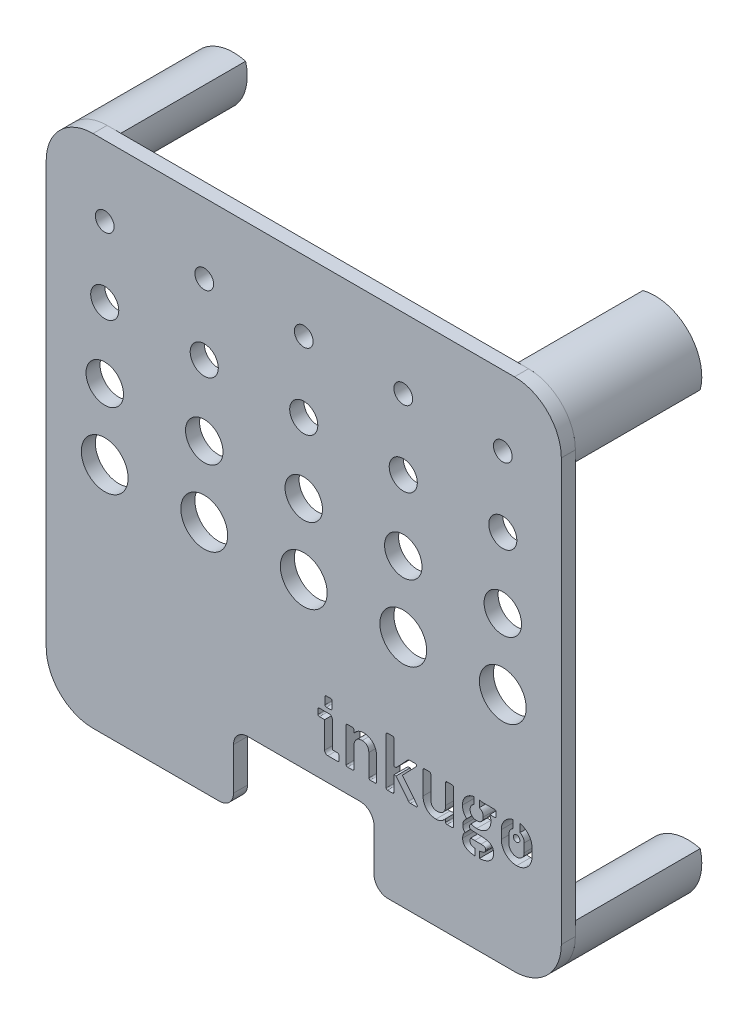
from build123d import *

# Parameters (mm, degrees)
SKETCH1_W             = 110
SKETCH1_H             = 110
BOSS_EXTRUDE1_DEPTH   = 3
FILLET1_R             = 10
SKETCH4_R             = 2
SKETCH4_R_2           = 3
SKETCH4_R_3           = 4
SKETCH4_R_4           = 5
CUT_EXTRUDE1_DEPTH    = 27
BOSS_EXTRUDE5_DEPTH   = 27
BOSS_EXTRUDE5_2_DEPTH = 27
BOSS_EXTRUDE5_3_DEPTH = 27
BOSS_EXTRUDE5_4_DEPTH = 27
SKETCH9_W             = 30
SKETCH9_H             = 15
CUT_EXTRUDE5_DEPTH    = 27
FILLET2_R             = 3
SKETCH10_W            = 1.094584863
SKETCH10_H            = 2.445349162
SKETCH10_W_2          = 0.908272546
SKETCH10_H_2          = 2.049435488
SKETCH10_W_3          = 1.479032729
SKETCH10_H_3          = 2.73682115
BOSS_EXTRUDE6_DEPTH   = 3
SKETCH12_R            = 0.7
CUT_EXTRUDE6_DEPTH    = 3


with BuildPart() as part:
    # Sketch1 → Boss-Extrude1 (new body)
    with BuildSketch(Plane.XY):
        with Locations((55, 55)):
            Rectangle(SKETCH1_W, SKETCH1_H)
    extrude(amount=BOSS_EXTRUDE1_DEPTH)

    # Fillet1
    fillet1_edges = [part.edges().sort_by_distance(p)[0] for p in [
        (0, 110, 1.5),
        (110, 110, 1.5),
        (110, 0, 1.5),
        (0, 0, 1.5),
    ]]
    fillet(fillet1_edges, radius=FILLET1_R)

    # Sketch4 → Cut-Extrude1 (cut)
    with BuildSketch(Plane.XY.offset(3)):
        with Locations((12.5, 95)):
            Circle(SKETCH4_R)
        with Locations((33.75, 95)):
            Circle(SKETCH4_R)
        with Locations((55, 95)):
            Circle(SKETCH4_R)
        with Locations((76.25, 95)):
            Circle(SKETCH4_R)
        with Locations((97.5, 95)):
            Circle(SKETCH4_R)
        with Locations((12.5, 80)):
            Circle(SKETCH4_R_2)
        with Locations((33.75, 80)):
            Circle(SKETCH4_R_2)
        with Locations((55, 80)):
            Circle(SKETCH4_R_2)
        with Locations((76.25, 80)):
            Circle(SKETCH4_R_2)
        with Locations((97.5, 80)):
            Circle(SKETCH4_R_2)
        with Locations((12.5, 65)):
            Circle(SKETCH4_R_3)
        with Locations((33.75, 65)):
            Circle(SKETCH4_R_3)
        with Locations((55, 65)):
            Circle(SKETCH4_R_3)
        with Locations((76.25, 65)):
            Circle(SKETCH4_R_3)
        with Locations((97.5, 65)):
            Circle(SKETCH4_R_3)
        with Locations((12.5, 50)):
            Circle(SKETCH4_R_4)
        with Locations((33.75, 50)):
            Circle(SKETCH4_R_4)
        with Locations((55, 50)):
            Circle(SKETCH4_R_4)
        with Locations((76.25, 50)):
            Circle(SKETCH4_R_4)
        with Locations((97.5, 50)):
            Circle(SKETCH4_R_4)
        with BuildLine():
            add(Edge.make_bspline(
                [(59.813195025, 28.814448571), (59.774303985, 28.817837787), (59.697575515, 28.824524402), (59.601057708, 28.89121158), (59.53437053, 28.987729387), (59.527683915, 29.064457856), (59.524294699, 29.103348897)],
                knots=[0, 0, 0, 0, 1.013731688, 2, 2.986268312, 4, 4, 4, 4], degree=3))
            Line((59.524294699, 29.103348897), (59.524294699, 30.603638177))
            add(Edge.make_bspline(
                [(59.524294699, 30.603638177), (59.52751846, 30.642657736), (59.533832298, 30.719078753), (59.602371745, 30.813729113), (59.696828985, 30.882905841), (59.774179126, 30.889308806), (59.813195025, 30.892538503)],
                knots=[0, 0, 0, 0, 1.014955419, 1.987821677, 2.985044581, 4, 4, 4, 4], degree=3))
            Line((59.813195025, 30.892538503), (60.749630565, 30.892538503))
            add(Edge.make_bspline(
                [(60.749630565, 30.892538503), (60.788777767, 30.889475105), (60.865830971, 30.883445439), (60.958398815, 30.812406427), (61.029437827, 30.719838582), (61.035467494, 30.642785379), (61.038530891, 30.603638177)],
                knots=[0, 0, 0, 0, 1.016108355, 2, 2.983891645, 4, 4, 4, 4], degree=3))
            Line((61.038530891, 30.603638177), (61.038530891, 29.103348897))
            add(Edge.make_bspline(
                [(61.038530891, 29.103348897), (61.035301195, 29.064332998), (61.028898229, 28.986982857), (60.959721501, 28.892525617), (60.865071142, 28.823986169), (60.788650124, 28.817672332), (60.749630565, 28.814448571)],
                knots=[0, 0, 0, 0, 1.014955419, 2.012178323, 2.985044581, 4, 4, 4, 4], degree=3))
            Line((60.749630565, 28.814448571), (59.813195025, 28.814448571))
        make_face()
        with BuildLine():
            add(Edge.make_bspline(
                [(60.143936088, 20), (60.097149113, 20.001952563), (60.005903239, 20.005760531), (59.87588171, 20.045715089), (59.756976775, 20.108749709), (59.653128255, 20.196539005), (59.564651268, 20.300749593), (59.502772585, 20.42092528), (59.462225241, 20.551297895), (59.458475341, 20.642573653), (59.456552553, 20.689375951)],
                knots=[0, 0, 0, 0, 1.032776546, 2.01416311, 2.980907915, 3.993505528, 5.006103142, 5.98583689, 6.967223454, 8, 8, 8, 8], degree=3))
            Line((59.456552553, 20.689375951), (59.456552553, 26.321936102))
            Line((59.456552553, 26.321936102), (58.34079957, 26.321936102))
            add(Edge.make_bspline(
                [(58.34079957, 26.321936102), (58.301213268, 26.325213521), (58.223757812, 26.331626194), (58.126666602, 26.398699201), (58.059983494, 26.495216895), (58.053296325, 26.57194538), (58.049906828, 26.610836428)],
                knots=[0, 0, 0, 0, 1.026560713, 2.008592011, 2.990623309, 4, 4, 4, 4], degree=3))
            Line((58.049906828, 26.610836428), (58.049906828, 27.601067201))
            add(Edge.make_bspline(
                [(58.049906828, 27.601067201), (58.05301505, 27.640785094), (58.059052727, 27.717936537), (58.127978767, 27.813155695), (58.223004026, 27.882722696), (58.301085378, 27.88884565), (58.34079957, 27.891959943)],
                knots=[0, 0, 0, 0, 1.023392815, 1.98792599, 2.976607185, 4, 4, 4, 4], degree=3))
            Line((58.34079957, 27.891959943), (60.418889502, 27.891959943))
            add(Edge.make_bspline(
                [(60.418889502, 27.891959943), (60.465648191, 27.889957377), (60.556838902, 27.886051891), (60.687563383, 27.846705021), (60.805212598, 27.780784126), (60.910029076, 27.693723567), (60.997089635, 27.588907088), (61.06301053, 27.471257873), (61.102357401, 27.340533393), (61.106262887, 27.249342682), (61.108265452, 27.202583993)],
                knots=[0, 0, 0, 0, 1.032642017, 2.013900747, 2.987534287, 4, 5.012465713, 5.986099253, 6.967357983, 8, 8, 8, 8], degree=3))
            Line((61.108265452, 27.202583993), (61.108265452, 21.570023841))
            Line((61.108265452, 21.570023841), (62.224018436, 21.570023841))
            add(Edge.make_bspline(
                [(62.224018436, 21.570023841), (62.263165638, 21.566960444), (62.340218842, 21.560930778), (62.432786686, 21.489891766), (62.503825698, 21.397323921), (62.509855365, 21.320270717), (62.512918762, 21.281123515)],
                knots=[0, 0, 0, 0, 1.016108355, 2, 2.983891645, 4, 4, 4, 4], degree=3))
            Line((62.512918762, 21.281123515), (62.512918762, 20.288900326))
            add(Edge.make_bspline(
                [(62.512918762, 20.288900326), (62.509689066, 20.249884428), (62.5032861, 20.172534286), (62.434109373, 20.078077046), (62.339459013, 20.009537599), (62.263037995, 20.003223762), (62.224018436, 20)],
                knots=[0, 0, 0, 0, 1.014955419, 2.012178323, 2.985044581, 4, 4, 4, 4], degree=3))
            Line((62.224018436, 20), (60.143936088, 20))
        make_face()
        with BuildLine():
            add(Edge.make_bspline(
                [(64.345941521, 20), (64.307050481, 20.003389217), (64.230322011, 20.010075831), (64.133804204, 20.076763009), (64.067117026, 20.173280816), (64.060430411, 20.250009286), (64.057041195, 20.288900326)],
                knots=[0, 0, 0, 0, 1.013731688, 2, 2.986268312, 4, 4, 4, 4], degree=3))
            Line((64.057041195, 20.288900326), (64.057041195, 27.601067201))
            add(Edge.make_bspline(
                [(64.057041195, 27.601067201), (64.060149052, 27.640785184), (64.066186021, 27.717936802), (64.135117181, 27.813154695), (64.229575754, 27.882326213), (64.306925714, 27.888729889), (64.345941521, 27.891959943)],
                knots=[0, 0, 0, 0, 1.0277946, 1.996476396, 2.989410076, 4, 4, 4, 4], degree=3))
            Line((64.345941521, 27.891959943), (65.419853768, 27.891959943))
            add(Edge.make_bspline(
                [(65.419853768, 27.891959943), (65.459702395, 27.889015996), (65.537490317, 27.883269159), (65.630621551, 27.811834984), (65.702055726, 27.718703751), (65.707802562, 27.640915829), (65.71074651, 27.601067201)],
                knots=[0, 0, 0, 0, 1.024545367, 2, 2.975454633, 4, 4, 4, 4], degree=3))
            Line((65.71074651, 27.601067201), (65.71074651, 26.955524403))
            add(Edge.make_bspline(
                [(65.71074651, 26.955524403), (65.776142481, 27.039308866), (65.905149694, 27.20459122), (66.125905145, 27.42523996), (66.366488314, 27.614491176), (66.62185048, 27.777429803), (66.893680098, 27.907978735), (67.180170617, 28.001835245), (67.480324774, 28.059884689), (67.684968613, 28.066120141), (67.788836442, 28.069284971)],
                knots=[0, 0, 0, 0, 1.040903831, 2.053400231, 3.049552216, 4.035445337, 5.016514275, 5.996222133, 6.982974232, 8, 8, 8, 8], degree=3))
            add(Edge.make_bspline(
                [(67.788836442, 28.069284971), (67.916691909, 28.064763318), (68.167724069, 28.055885479), (68.533558681, 27.983702214), (68.880277739, 27.868587069), (69.202731256, 27.703444303), (69.50042083, 27.501032493), (69.766417613, 27.258741642), (69.999113949, 26.980330066), (70.193120139, 26.666157945), (70.351680743, 26.326403935), (70.462664796, 25.9615246), (70.532952217, 25.57683028), (70.540502967, 25.312756393), (70.544347828, 25.178289294)],
                knots=[0, 0, 0, 0, 1.03012054, 2.022544607, 2.994518876, 3.966788102, 4.93368984, 5.888941106, 6.858389822, 7.849426085, 8.858084892, 9.872625224, 10.91673532, 12, 12, 12, 12], degree=3))
            Line((70.544347828, 25.178289294), (70.544347828, 20.288900326))
            add(Edge.make_bspline(
                [(70.544347828, 20.288900326), (70.541118132, 20.249884428), (70.534715166, 20.172534286), (70.465538439, 20.078077046), (70.370888079, 20.009537599), (70.294467061, 20.003223762), (70.255447502, 20)],
                knots=[0, 0, 0, 0, 1.014955419, 2.012178323, 2.985044581, 4, 4, 4, 4], degree=3))
            Line((70.255447502, 20), (69.179542839, 20))
            add(Edge.make_bspline(
                [(69.179542839, 20), (69.140651799, 20.003389217), (69.063923329, 20.010075831), (68.967405523, 20.076763009), (68.900718344, 20.173280816), (68.89403173, 20.250009286), (68.890642513, 20.288900326)],
                knots=[0, 0, 0, 0, 1.013731688, 2, 2.986268312, 4, 4, 4, 4], degree=3))
            Line((68.890642513, 20.288900326), (68.890642513, 24.971078025))
            add(Edge.make_bspline(
                [(68.890642513, 24.971078025), (68.88961417, 25.03024437), (68.887610254, 25.145540837), (68.868692887, 25.312527165), (68.842028807, 25.470292417), (68.800138161, 25.616149419), (68.747624905, 25.752272056), (68.684663365, 25.877842643), (68.607906751, 25.992526943), (68.52034655, 26.096123981), (68.422151044, 26.188513049), (68.314094561, 26.268109649), (68.197428767, 26.336588446), (68.071437182, 26.393149849), (67.934358823, 26.433618393), (67.788859268, 26.466658685), (67.633175879, 26.483843793), (67.526536561, 26.486135525), (67.472042291, 26.487306633)],
                knots=[0, 0, 0, 0, 1.20144891, 2.341243424, 3.410417786, 4.448231723, 5.417856885, 6.371200576, 7.295460221, 8.214486023, 9.121248957, 10.027911514, 10.934975516, 11.865124725, 12.825317511, 13.833595538, 14.892935253, 16, 16, 16, 16], degree=3))
            add(Edge.make_bspline(
                [(67.472042291, 26.487306633), (67.406193538, 26.486041711), (67.277278098, 26.483565307), (67.089264671, 26.456376561), (66.911522167, 26.415425704), (66.744700397, 26.356919245), (66.587626292, 26.283371975), (66.442045627, 26.19052125), (66.30505073, 26.083108921), (66.182327072, 25.956496454), (66.070958023, 25.818093201), (65.974197112, 25.666440631), (65.892103042, 25.503044352), (65.827737847, 25.325909219), (65.771677123, 25.138287283), (65.738344382, 24.936809871), (65.715241311, 24.723892253), (65.712274055, 24.577977327), (65.71074651, 24.502860255)],
                knots=[0, 0, 0, 0, 1.052956461, 2.061426214, 3.033224436, 3.967576965, 4.885035783, 5.802002071, 6.724800171, 7.664155558, 8.616822253, 9.563125276, 10.537418938, 11.536211118, 12.575565151, 13.665830152, 14.798368278, 16, 16, 16, 16], degree=3))
            Line((65.71074651, 24.502860255), (65.71074651, 20.288900326))
            add(Edge.make_bspline(
                [(65.71074651, 20.288900326), (65.707516456, 20.249884519), (65.70111278, 20.172534559), (65.631941262, 20.078075986), (65.536723369, 20.009144826), (65.459571751, 20.003107857), (65.419853768, 20)],
                knots=[0, 0, 0, 0, 1.010589924, 2.003523604, 2.9722054, 4, 4, 4, 4], degree=3))
            Line((65.419853768, 20), (64.345941521, 20))
        make_face()
        with BuildLine():
            add(Edge.make_bspline(
                [(72.88942151, 20), (72.850530469, 20.003389217), (72.773802, 20.010075831), (72.677284193, 20.076763009), (72.610597015, 20.173280816), (72.6039104, 20.250009286), (72.600521184, 20.288900326)],
                knots=[0, 0, 0, 0, 1.013731688, 2, 2.986268312, 4, 4, 4, 4], degree=3))
            Line((72.600521184, 20.288900326), (72.600521184, 30.258950201))
            add(Edge.make_bspline(
                [(72.600521184, 30.258950201), (72.603629041, 30.298668185), (72.60966601, 30.375819803), (72.67859717, 30.471037696), (72.773055743, 30.540209214), (72.850405703, 30.546612889), (72.88942151, 30.549842943)],
                knots=[0, 0, 0, 0, 1.0277946, 1.996476396, 2.989410076, 4, 4, 4, 4], degree=3))
            Line((72.88942151, 30.549842943), (73.963333757, 30.549842943))
            add(Edge.make_bspline(
                [(73.963333757, 30.549842943), (74.003182384, 30.546898996), (74.080970306, 30.541152159), (74.17410154, 30.469717984), (74.245535715, 30.376586751), (74.251282551, 30.298798829), (74.254226499, 30.258950201)],
                knots=[0, 0, 0, 0, 1.024545367, 2, 2.975454633, 4, 4, 4, 4], degree=3))
            Line((74.254226499, 30.258950201), (74.254226499, 25.082653324))
            Line((74.254226499, 25.082653324), (74.722444269, 25.082653324))
            Line((74.722444269, 25.082653324), (77.187062913, 27.726589412))
            add(Edge.make_bspline(
                [(77.187062913, 27.726589412), (77.21262253, 27.751799795), (77.262866252, 27.80135701), (77.354379831, 27.852315036), (77.452855262, 27.887442516), (77.522133053, 27.890428835), (77.557652297, 27.891959943)],
                knots=[0, 0, 0, 0, 1.026908898, 2.018642276, 2.984143038, 4, 4, 4, 4], degree=3))
            Line((77.557652297, 27.891959943), (78.810881987, 27.891959943))
            add(Edge.make_bspline(
                [(78.810881987, 27.891959943), (78.850544242, 27.889463647), (78.92695236, 27.88465461), (79.020385055, 27.820745375), (79.09212669, 27.736471511), (79.09855565, 27.664832017), (79.101774729, 27.628961026)],
                knots=[0, 0, 0, 0, 1.072887516, 2.066884899, 3.032059675, 4, 4, 4, 4], degree=3))
            add(Edge.make_bspline(
                [(79.101774729, 27.628961026), (79.097586206, 27.59480189), (79.088312066, 27.519167449), (79.04296178, 27.457537759), (79.018093256, 27.423742173)],
                knots=[0, 0, 0, 0, 0.903269317, 2, 2, 2, 2], degree=3))
            Line((79.018093256, 27.423742173), (76.057363017, 24.337489724))
            Line((76.057363017, 24.337489724), (79.197410699, 20.426377033))
            add(Edge.make_bspline(
                [(79.197410699, 20.426377033), (79.217444635, 20.396861933), (79.254506488, 20.342260367), (79.263166468, 20.277029599), (79.267145261, 20.247059589)],
                knots=[0, 0, 0, 0, 1.081108168, 2, 2, 2, 2], degree=3))
            add(Edge.make_bspline(
                [(79.267145261, 20.247059589), (79.263891676, 20.213096579), (79.257582788, 20.147240354), (79.202177897, 20.061468663), (79.111263916, 20.00897846), (79.041378526, 20.003120755), (79.004146343, 20)],
                knots=[0, 0, 0, 0, 1.000464213, 1.939957509, 2.902490516, 4, 4, 4, 4], degree=3))
            Line((79.004146343, 20), (77.778810477, 20))
            add(Edge.make_bspline(
                [(77.778810477, 20), (77.737375925, 20.002936805), (77.656041267, 20.008701655), (77.539363149, 20.04675957), (77.436913967, 20.115636745), (77.381154956, 20.176077953), (77.352433444, 20.207211268)],
                knots=[0, 0, 0, 0, 1.014431785, 1.991296106, 2.965314988, 4, 4, 4, 4], degree=3))
            Line((77.352433444, 20.207211268), (74.708497356, 23.538530891))
            Line((74.708497356, 23.538530891), (74.254226499, 23.538530891))
            Line((74.254226499, 23.538530891), (74.254226499, 20.288900326))
            add(Edge.make_bspline(
                [(74.254226499, 20.288900326), (74.250996444, 20.249884519), (74.244592769, 20.172534559), (74.175421251, 20.078075986), (74.080203358, 20.009144826), (74.00305174, 20.003107857), (73.963333757, 20)],
                knots=[0, 0, 0, 0, 1.010589924, 2.003523604, 2.9722054, 4, 4, 4, 4], degree=3))
            Line((73.963333757, 20), (72.88942151, 20))
        make_face()
        with BuildLine():
            add(Edge.make_bspline(
                [(83.224083521, 19.820682556), (83.096229221, 19.825198433), (82.845199353, 19.834064931), (82.47872805, 19.906452794), (82.131786608, 20.021482479), (81.807092662, 20.183950976), (81.511258237, 20.388657783), (81.246397905, 20.631784134), (81.013736419, 20.909584147), (80.819862027, 21.223837252), (80.660788702, 21.564083209), (80.550604696, 21.929881443), (80.4799058, 22.315110534), (80.472396095, 22.579197096), (80.468572134, 22.713670649)],
                knots=[0, 0, 0, 0, 1.029531539, 2.021388161, 2.997879315, 3.967187475, 4.936569502, 5.887321453, 6.85621586, 7.84668547, 8.854767548, 9.87384161, 10.917354707, 12, 12, 12, 12], degree=3))
            Line((80.468572134, 22.713670649), (80.468572134, 27.601067201))
            add(Edge.make_bspline(
                [(80.468572134, 27.601067201), (80.471679992, 27.640785184), (80.47771696, 27.717936802), (80.54664812, 27.813154695), (80.641106694, 27.882326213), (80.718456654, 27.888729889), (80.75747246, 27.891959943)],
                knots=[0, 0, 0, 0, 1.0277946, 1.996476396, 2.989410076, 4, 4, 4, 4], degree=3))
            Line((80.75747246, 27.891959943), (81.831384707, 27.891959943))
            add(Edge.make_bspline(
                [(81.831384707, 27.891959943), (81.871233335, 27.889015996), (81.949021257, 27.883269159), (82.04215249, 27.811834984), (82.113586665, 27.718703751), (82.119333502, 27.640915829), (82.122277449, 27.601067201)],
                knots=[0, 0, 0, 0, 1.024545367, 2, 2.975454633, 4, 4, 4, 4], degree=3))
            Line((82.122277449, 27.601067201), (82.122277449, 22.918889502))
            add(Edge.make_bspline(
                [(82.122277449, 22.918889502), (82.123253477, 22.859715573), (82.125144548, 22.745064997), (82.144684179, 22.578183221), (82.170252476, 22.420845208), (82.213242516, 22.275291245), (82.265103633, 22.139581247), (82.328620011, 22.014785944), (82.402740444, 21.898818165), (82.490705863, 21.795904586), (82.588785807, 21.703502127), (82.697134013, 21.623218032), (82.815160693, 21.555946261), (82.941428501, 21.498715687), (83.07857667, 21.458368561), (83.224056235, 21.425293502), (83.379745281, 21.408118233), (83.486383807, 21.405825123), (83.540877671, 21.40465331)],
                knots=[0, 0, 0, 0, 1.202114207, 2.329118383, 3.412174328, 4.437583134, 5.407745221, 6.361616823, 7.278969009, 8.198503717, 9.105768768, 10.012933385, 10.932170781, 11.862835056, 12.823559545, 13.832395901, 14.892322221, 16, 16, 16, 16], degree=3))
            add(Edge.make_bspline(
                [(83.540877671, 21.40465331), (83.60674169, 21.405858976), (83.735687015, 21.408219371), (83.922696667, 21.436122178), (84.101269972, 21.474028436), (84.267210252, 21.535343074), (84.425027035, 21.607876193), (84.569210125, 21.702048119), (84.705180589, 21.808827303), (84.829405184, 21.933396048), (84.939557249, 22.072594795), (85.039159957, 22.222828187), (85.120455991, 22.387078423), (85.185979075, 22.563646942), (85.237924203, 22.752304143), (85.275499001, 22.952845457), (85.297424078, 23.166127788), (85.300559392, 23.312008047), (85.302173453, 23.387107272)],
                knots=[0, 0, 0, 0, 1.053674742, 2.062832429, 3.022533671, 3.971093134, 4.889177802, 5.797790087, 6.721217679, 7.653664046, 8.606980608, 9.559703832, 10.534662115, 11.534135627, 12.571313147, 13.664237883, 14.797548578, 16, 16, 16, 16], degree=3))
            Line((85.302173453, 23.387107272), (85.302173453, 27.601067201))
            add(Edge.make_bspline(
                [(85.302173453, 27.601067201), (85.30528131, 27.640785184), (85.311318279, 27.717936802), (85.380249439, 27.813154695), (85.474708012, 27.882326213), (85.552057972, 27.888729889), (85.591073779, 27.891959943)],
                knots=[0, 0, 0, 0, 1.0277946, 1.996476396, 2.989410076, 4, 4, 4, 4], degree=3))
            Line((85.591073779, 27.891959943), (86.666978442, 27.891959943))
            add(Edge.make_bspline(
                [(86.666978442, 27.891959943), (86.706125456, 27.888896111), (86.783178289, 27.882865589), (86.875748842, 27.811832838), (86.947189299, 27.718704319), (86.952935266, 27.640916021), (86.955878768, 27.601067201)],
                knots=[0, 0, 0, 0, 1.011732958, 1.991387932, 2.971042906, 4, 4, 4, 4], degree=3))
            Line((86.955878768, 27.601067201), (86.955878768, 20.288900326))
            add(Edge.make_bspline(
                [(86.955878768, 20.288900326), (86.952649071, 20.249884428), (86.946246106, 20.172534286), (86.877069378, 20.078077046), (86.782419018, 20.009537599), (86.705998001, 20.003223762), (86.666978442, 20)],
                knots=[0, 0, 0, 0, 1.014955419, 2.012178323, 2.985044581, 4, 4, 4, 4], degree=3))
            Line((86.666978442, 20), (85.591073779, 20))
            add(Edge.make_bspline(
                [(85.591073779, 20), (85.552182738, 20.003389217), (85.475454269, 20.010075831), (85.378936462, 20.076763009), (85.312249284, 20.173280816), (85.305562669, 20.250009286), (85.302173453, 20.288900326)],
                knots=[0, 0, 0, 0, 1.013731688, 2, 2.986268312, 4, 4, 4, 4], degree=3))
            Line((85.302173453, 20.288900326), (85.302173453, 20.93643554))
            add(Edge.make_bspline(
                [(85.302173453, 20.93643554), (85.236801966, 20.852622204), (85.107843052, 20.687282892), (84.88644096, 20.466757483), (84.646517366, 20.275534891), (84.391563338, 20.110491404), (84.119581646, 19.97952191), (83.832350763, 19.888718351), (83.532646165, 19.829920305), (83.327968512, 19.823792665), (83.224083521, 19.820682556)],
                knots=[0, 0, 0, 0, 1.040184036, 2.051980287, 3.05149353, 4.040198147, 5.020588668, 5.997607763, 6.983677514, 8, 8, 8, 8], degree=3))
        make_face()
        with BuildLine():
            add(Edge.make_bspline(
                [(91.944888537, 17.148852644), (91.833280743, 17.150503394), (91.615159095, 17.153729552), (91.296505841, 17.175316414), (90.995092715, 17.212816606), (90.711364177, 17.265972103), (90.445484872, 17.336530274), (90.195585277, 17.418801352), (89.964282424, 17.519378177), (89.749409274, 17.631140197), (89.557906377, 17.76337852), (89.387863357, 17.910082808), (89.247858306, 18.078382741), (89.130193939, 18.260961193), (89.040417346, 18.462038945), (88.977304914, 18.679971955), (88.935635836, 18.91387416), (88.932151364, 19.075996244), (88.930363066, 19.15920043)],
                knots=[0, 0, 0, 0, 1.309557742, 2.559345399, 3.745333508, 4.871733681, 5.943460254, 6.971073302, 7.955434123, 8.900193972, 9.808044252, 10.680417822, 11.526535541, 12.367469814, 13.22201464, 14.099801128, 15.024781231, 16, 16, 16, 16], degree=3))
            add(Edge.make_bspline(
                [(88.930363066, 19.15920043), (88.931871891, 19.221700814), (88.934836803, 19.344516982), (88.958968736, 19.525560146), (89.001236041, 19.699559226), (89.059297438, 19.866693944), (89.1310594, 20.028278416), (89.221609838, 20.182330927), (89.329456838, 20.329629788), (89.411109426, 20.421690789), (89.452376069, 20.46821777)],
                knots=[0, 0, 0, 0, 1.03764953, 2.03902969, 3.026095819, 4.006174766, 4.97370049, 5.957310148, 6.967638938, 8, 8, 8, 8], degree=3))
            add(Edge.make_bspline(
                [(89.452376069, 20.46821777), (89.412810574, 20.501688753), (89.334350347, 20.568063279), (89.235924601, 20.685545692), (89.149163872, 20.808822492), (89.078107989, 20.942365727), (89.024845486, 21.085946108), (88.987423647, 21.239123515), (88.962392056, 21.401180498), (88.959658113, 21.512810377), (88.95825689, 21.570023841)],
                knots=[0, 0, 0, 0, 0.992569303, 1.968311382, 2.929721406, 3.881627407, 4.861437691, 5.859634357, 6.903002194, 8, 8, 8, 8], degree=3))
            add(Edge.make_bspline(
                [(88.95825689, 21.570023841), (88.960662551, 21.647304846), (88.965451322, 21.801142438), (89.012604836, 22.027451203), (89.081091057, 22.249172041), (89.18260639, 22.461097044), (89.304468238, 22.665211313), (89.454448213, 22.851320996), (89.619667423, 23.028641082), (89.746545314, 23.130257785), (89.811010956, 23.181888419)],
                knots=[0, 0, 0, 0, 0.980363973, 1.951538199, 2.925346916, 3.921696138, 4.928667228, 5.93789737, 6.952262145, 8, 8, 8, 8], degree=3))
            add(Edge.make_bspline(
                [(89.811010956, 23.181888419), (89.740417336, 23.245444487), (89.599736648, 23.37210057), (89.4161013, 23.589224384), (89.258007039, 23.826289275), (89.123778815, 24.081584868), (89.018837087, 24.354502202), (88.942343524, 24.640869668), (88.898434847, 24.939836412), (88.891859404, 25.142950068), (88.888522329, 25.246031439)],
                knots=[0, 0, 0, 0, 0.975475713, 1.943951805, 2.913317632, 3.899554035, 4.902307536, 5.912353716, 6.940507277, 8, 8, 8, 8], degree=3))
            add(Edge.make_bspline(
                [(88.888522329, 25.246031439), (88.893462353, 25.382526811), (88.903133018, 25.649732171), (88.980039711, 26.037998734), (89.109369841, 26.40120558), (89.286433811, 26.73818666), (89.508963853, 27.043173022), (89.767486852, 27.315708788), (90.065272241, 27.547466163), (90.395230847, 27.740711667), (90.751406228, 27.893744635), (91.129373437, 28.003620164), (91.525395025, 28.071039191), (91.795855682, 28.079130793), (91.932934041, 28.083231883)],
                knots=[0, 0, 0, 0, 1.05469476, 2.064686079, 3.045584585, 4.026294936, 4.99684501, 5.955588664, 6.921100423, 7.903851684, 8.904362384, 9.910116178, 10.940778123, 12, 12, 12, 12], degree=3))
            add(Edge.make_bspline(
                [(91.932934041, 28.083231883), (92.03267009, 28.080983681), (92.230798814, 28.076517557), (92.523968549, 28.039230081), (92.811003921, 27.9807155), (92.996014042, 27.921548592), (93.088535346, 27.891959943)],
                knots=[0, 0, 0, 0, 1.016908952, 2.020120848, 3.0098866, 4, 4, 4, 4], degree=3))
            Line((93.088535346, 27.891959943), (95.802205995, 27.891959943))
            add(Edge.make_bspline(
                [(95.802205995, 27.891959943), (95.841353009, 27.888896111), (95.918405843, 27.882865589), (96.010976395, 27.811832838), (96.082416852, 27.718704319), (96.088162819, 27.640916021), (96.091106321, 27.601067201)],
                knots=[0, 0, 0, 0, 1.011732958, 1.991387932, 2.971042906, 4, 4, 4, 4], degree=3))
            Line((96.091106321, 27.601067201), (96.091106321, 26.692525486))
            add(Edge.make_bspline(
                [(96.091106321, 26.692525486), (96.087876625, 26.653509587), (96.081473659, 26.576159445), (96.012296932, 26.481702206), (95.917646572, 26.413162758), (95.841225554, 26.406848921), (95.802205995, 26.40362516)],
                knots=[0, 0, 0, 0, 1.014955419, 2.012178323, 2.985044581, 4, 4, 4, 4], degree=3))
            Line((95.802205995, 26.40362516), (94.728293748, 26.40362516))
            add(Edge.make_bspline(
                [(94.728293748, 26.40362516), (94.764172418, 26.313311395), (94.836303885, 26.131742108), (94.908422196, 25.845413615), (94.954145158, 25.549041004), (94.958967243, 25.34781746), (94.961406425, 25.246031439)],
                knots=[0, 0, 0, 0, 0.979987643, 1.970194221, 2.973252086, 4, 4, 4, 4], degree=3))
            add(Edge.make_bspline(
                [(94.961406425, 25.246031439), (94.956447609, 25.112186127), (94.946718492, 24.84958379), (94.869579473, 24.467320832), (94.740489862, 24.10872381), (94.56359367, 23.775489935), (94.340207441, 23.475250586), (94.084742276, 23.203874926), (93.787472348, 22.974976444), (93.461870305, 22.77930863), (93.107956004, 22.625914898), (92.733149496, 22.516641093), (92.339196745, 22.448631163), (92.070024005, 22.440742516), (91.932934041, 22.43672482)],
                knots=[0, 0, 0, 0, 1.043186406, 2.046714847, 3.026384337, 4.006464447, 4.977083997, 5.936837178, 6.903469001, 7.892946328, 8.892645159, 9.902169801, 10.931572845, 12, 12, 12, 12], degree=3))
            add(Edge.make_bspline(
                [(91.932934041, 22.43672482), (91.827173566, 22.439291202), (91.616154845, 22.444411779), (91.301309783, 22.489577421), (90.986939205, 22.554463214), (90.782719763, 22.623206492), (90.679704351, 22.657883)],
                knots=[0, 0, 0, 0, 0.992067919, 1.979424765, 2.98075134, 4, 4, 4, 4], degree=3))
            add(Edge.make_bspline(
                [(90.679704351, 22.657883), (90.635146312, 22.610973241), (90.550444693, 22.52180117), (90.460277332, 22.368426591), (90.398792829, 22.212832832), (90.392105241, 22.105198402), (90.388811608, 22.052188523)],
                knots=[0, 0, 0, 0, 1.122370757, 2.133545889, 3.080772711, 4, 4, 4, 4], degree=3))
            add(Edge.make_bspline(
                [(90.388811608, 22.052188523), (90.391297179, 22.009330534), (90.395920116, 21.929618532), (90.435249802, 21.819147471), (90.502330216, 21.730456845), (90.599229978, 21.667644632), (90.716632299, 21.620676368), (90.858060173, 21.587416217), (91.021248109, 21.555622258), (91.139114819, 21.546810307), (91.201717354, 21.542130017)],
                knots=[0, 0, 0, 0, 0.951285315, 1.769305018, 2.570197876, 3.377606579, 4.305069671, 5.373017677, 6.604731118, 8, 8, 8, 8], degree=3))
            add(Edge.make_bspline(
                [(91.201717354, 21.542130017), (91.386987078, 21.534491354), (91.758753775, 21.519163431), (92.130822069, 21.515882216), (92.317470337, 21.514236192)],
                knots=[0, 0, 0, 0, 0.996698877, 2, 2, 2, 2], degree=3))
            Line((92.317470337, 21.514236192), (92.937111726, 21.50028928))
            add(Edge.make_bspline(
                [(92.937111726, 21.50028928), (93.031476333, 21.497280594), (93.215827201, 21.491402821), (93.484954854, 21.466417441), (93.740512438, 21.43366733), (93.982679535, 21.38770186), (94.210804882, 21.330244917), (94.426043102, 21.26250375), (94.627237375, 21.182879305), (94.815468154, 21.092490894), (94.986564105, 20.985342291), (95.13730903, 20.856933922), (95.2608571, 20.702878516), (95.363793694, 20.529294129), (95.443947425, 20.334093998), (95.498140646, 20.117290941), (95.532818757, 19.87957078), (95.537016362, 19.713887652), (95.539207077, 19.6274182)],
                knots=[0, 0, 0, 0, 1.238197474, 2.418944841, 3.543863457, 4.616881487, 5.650117501, 6.628222895, 7.574620503, 8.486339379, 9.363652491, 10.215997797, 11.070477527, 11.941539541, 12.855627871, 13.827622844, 14.866243862, 16, 16, 16, 16], degree=3))
            add(Edge.make_bspline(
                [(95.539207077, 19.6274182), (95.536152025, 19.526955814), (95.530210586, 19.331577436), (95.483977834, 19.048339131), (95.406535465, 18.784804904), (95.295671951, 18.540761566), (95.153133013, 18.316492443), (94.980151407, 18.110755094), (94.774183353, 17.927214565), (94.540637011, 17.762012155), (94.281743005, 17.618245489), (94.002890261, 17.49252401), (93.706264949, 17.384345462), (93.389183589, 17.299689284), (93.054400963, 17.232486581), (92.701321405, 17.181949378), (92.329188267, 17.154935418), (92.075099847, 17.150913655), (91.944888537, 17.148852644)],
                knots=[0, 0, 0, 0, 0.980623221, 1.907107538, 2.79350449, 3.655461654, 4.515440476, 5.380660519, 6.271459074, 7.201748643, 8.168637451, 9.15833231, 10.186112998, 11.248026821, 12.359611279, 13.518866834, 14.72850719, 16, 16, 16, 16], degree=3))
        make_face()
        with BuildLine():
            add(Edge.make_bspline(
                [(91.932934041, 23.883218866), (92.034976191, 23.887557002), (92.231035328, 23.895892098), (92.508232299, 23.966243827), (92.751838874, 24.083304057), (92.957482175, 24.247119843), (93.123166376, 24.449928093), (93.239386916, 24.688860135), (93.311227642, 24.957658348), (93.319389035, 25.147263168), (93.323640439, 25.246031439)],
                knots=[0, 0, 0, 0, 1.11287458, 2.138226504, 3.098184256, 4.042680072, 4.986061768, 5.933004036, 6.923267786, 8, 8, 8, 8], degree=3))
            add(Edge.make_bspline(
                [(93.323640439, 25.246031439), (93.319401332, 25.345460764), (93.311262123, 25.53636795), (93.239080405, 25.807691467), (93.122762896, 26.050028781), (92.985200058, 26.224545246), (92.854626868, 26.343064715), (92.749586916, 26.424672462), (92.632574536, 26.488500035), (92.510658399, 26.546709288), (92.377592288, 26.587606049), (92.23683518, 26.617009581), (92.087504534, 26.635616265), (91.985456666, 26.637672128), (91.932934041, 26.638730253)],
                knots=[0, 0, 0, 0, 1.61016637, 3.091566112, 4.517533475, 5.944110964, 6.660726596, 7.375964664, 8.094762763, 8.817745571, 9.563791271, 10.345456871, 11.148429553, 12, 12, 12, 12], degree=3))
            add(Edge.make_bspline(
                [(91.932934041, 26.638730253), (91.880413543, 26.637640675), (91.777710265, 26.635510018), (91.627700412, 26.617160336), (91.486210195, 26.58775899), (91.352321649, 26.545758388), (91.228172093, 26.489566098), (91.110290228, 26.424622443), (91.005135065, 26.342486501), (90.872211426, 26.225224421), (90.73333967, 26.050043195), (90.614953844, 25.807905593), (90.540127448, 25.536651885), (90.53233539, 25.345499234), (90.528280731, 25.246031439)],
                knots=[0, 0, 0, 0, 0.847859521, 1.65798031, 2.436239612, 3.179034236, 3.918414409, 4.63408017, 5.346201415, 6.067629732, 7.494655642, 8.919140384, 10.396850321, 12, 12, 12, 12], degree=3))
            add(Edge.make_bspline(
                [(90.528280731, 25.246031439), (90.532344282, 25.147220359), (90.540152162, 24.957360532), (90.614679266, 24.688684019), (90.732802641, 24.44974658), (90.900567324, 24.2470876), (91.108508223, 24.082606031), (91.354737983, 23.967132729), (91.633413796, 23.895557325), (91.830197044, 23.887451021), (91.932934041, 23.883218866)],
                knots=[0, 0, 0, 0, 1.071950009, 2.059690492, 3.005655517, 3.949414207, 4.895379231, 5.864072975, 6.884870894, 8, 8, 8, 8], degree=3))
        make_face(mode=Mode.SUBTRACT)
        with BuildLine():
            add(Edge.make_bspline(
                [(92.070410748, 18.567452866), (92.142816689, 18.568283233), (92.282385231, 18.569883836), (92.485032352, 18.580278597), (92.673983516, 18.595051324), (92.84940767, 18.619383713), (93.010423699, 18.648703203), (93.157856882, 18.684188757), (93.290737663, 18.728283291), (93.411282928, 18.776506051), (93.515648581, 18.835974696), (93.608112315, 18.898099258), (93.684466877, 18.969812002), (93.750501746, 19.044840861), (93.797358143, 19.130667509), (93.835293242, 19.220902917), (93.854073276, 19.31984448), (93.857732402, 19.387607122), (93.859600354, 19.422199348)],
                knots=[0, 0, 0, 0, 1.580983636, 3.047478938, 4.430044814, 5.718031082, 6.912664638, 8.003018019, 9.02569154, 9.968321281, 10.831768712, 11.644398253, 12.393605671, 13.114049888, 13.815562867, 14.518423614, 15.243668421, 16, 16, 16, 16], degree=3))
            add(Edge.make_bspline(
                [(93.859600354, 19.422199348), (93.857582831, 19.477241148), (93.853828235, 19.579673527), (93.799460699, 19.717585141), (93.712705434, 19.826852474), (93.58618093, 19.895183077), (93.437346864, 19.943581246), (93.261598415, 19.975444843), (93.060582461, 19.998308972), (92.917267741, 19.999415051), (92.841475756, 20)],
                knots=[0, 0, 0, 0, 0.983187636, 1.829704878, 2.618124847, 3.436762005, 4.368869509, 5.426713209, 6.639117373, 8, 8, 8, 8], degree=3))
            Line((92.841475756, 20), (91.49061768, 20))
            add(Edge.make_bspline(
                [(91.49061768, 20), (91.409586217, 20.000202105), (91.254784031, 20.000588204), (91.034167007, 20.008351531), (90.8355055, 20.022173435), (90.710886343, 20.035515785), (90.651810526, 20.041840737)],
                knots=[0, 0, 0, 0, 1.157047795, 2.210419533, 3.151647873, 4, 4, 4, 4], degree=3))
            add(Edge.make_bspline(
                [(90.651810526, 20.041840737), (90.628625944, 19.999255808), (90.581906035, 19.913441712), (90.534181483, 19.771624378), (90.506415235, 19.619882859), (90.502420685, 19.515296561), (90.500386907, 19.462047669)],
                knots=[0, 0, 0, 0, 0.958127143, 1.930749142, 2.946465082, 4, 4, 4, 4], degree=3))
            add(Edge.make_bspline(
                [(90.500386907, 19.462047669), (90.501191751, 19.420098616), (90.502735072, 19.339659614), (90.524081478, 19.224140572), (90.554700146, 19.118516418), (90.599534196, 19.023481973), (90.654871424, 18.937860149), (90.727260971, 18.866202535), (90.808687295, 18.800629335), (90.943119753, 18.731188738), (91.139963836, 18.662348625), (91.411914302, 18.606184026), (91.726938152, 18.573905609), (91.951450046, 18.569687754), (92.070410748, 18.567452866)],
                knots=[0, 0, 0, 0, 0.73354101, 1.406594504, 2.050477934, 2.65402367, 3.241096148, 3.825049872, 4.429938813, 5.064831232, 6.462891627, 8.068803851, 9.917001863, 12, 12, 12, 12], degree=3))
        make_face(mode=Mode.SUBTRACT)
        with BuildLine():
            add(Edge.make_bspline(
                [(100.454497454, 19.820682556), (100.307993065, 19.826018344), (100.018638508, 19.83655683), (99.594501211, 19.921319898), (99.188435811, 20.05728939), (98.804290657, 20.247090064), (98.448914871, 20.483094767), (98.129273408, 20.760716318), (97.847208396, 21.075736823), (97.610522904, 21.428106515), (97.415236226, 21.805385299), (97.277959342, 22.20475057), (97.1929709, 22.619760142), (97.182342539, 22.901882676), (97.176973064, 23.044411712)],
                knots=[0, 0, 0, 0, 1.032620996, 2.039485608, 3.037880839, 4.045529682, 5.052394294, 6.038594437, 7.023948745, 8.025646133, 9.024931058, 10.011542728, 10.995426223, 12, 12, 12, 12], degree=3))
            Line((97.176973064, 23.044411712), (97.176973064, 24.847548231))
            add(Edge.make_bspline(
                [(97.176973064, 24.847548231), (97.182364567, 24.990069383), (97.193036528, 25.272176312), (97.27757691, 25.686683804), (97.41575373, 26.085050115), (97.610370797, 26.461962582), (97.84786198, 26.814330642), (98.128632493, 27.131105871), (98.448414207, 27.40898841), (98.8048537, 27.642794682), (99.188809085, 27.832046515), (99.593842273, 27.9718581), (100.018943231, 28.052590142), (100.3080534, 28.063671759), (100.454497454, 28.069284971)],
                knots=[0, 0, 0, 0, 1.004815596, 1.98893593, 2.971359466, 3.970884937, 4.972823452, 5.961916848, 6.948354388, 7.952874998, 8.9607664, 9.960906653, 10.967130434, 12, 12, 12, 12], degree=3))
            add(Edge.make_bspline(
                [(100.454497454, 28.069284971), (100.600941507, 28.063671759), (100.890051676, 28.052590142), (101.315152634, 27.9718581), (101.720185822, 27.832046515), (102.104141207, 27.642794682), (102.4605807, 27.40898841), (102.780362414, 27.131105871), (103.061132927, 26.814330642), (103.29862411, 26.461962582), (103.493241177, 26.085050115), (103.631417997, 25.686683804), (103.715958379, 25.272176312), (103.72663034, 24.990069383), (103.732021843, 24.847548231)],
                knots=[0, 0, 0, 0, 1.032869566, 2.039093347, 3.0392336, 4.047125002, 5.051645612, 6.038083152, 7.027176548, 8.029115063, 9.028640534, 10.01106407, 10.995184404, 12, 12, 12, 12], degree=3))
            Line((103.732021843, 24.847548231), (103.732021843, 23.044411712))
            add(Edge.make_bspline(
                [(103.732021843, 23.044411712), (103.726652368, 22.901882676), (103.716024007, 22.619760142), (103.631035565, 22.20475057), (103.493758681, 21.805385299), (103.298472003, 21.428106515), (103.061786511, 21.075736823), (102.779721499, 20.760716318), (102.460080036, 20.483094767), (102.10470425, 20.247090064), (101.720559096, 20.05728939), (101.314493696, 19.921319898), (100.890356399, 19.83655683), (100.601001842, 19.826018344), (100.454497454, 19.820682556)],
                knots=[0, 0, 0, 0, 1.004573777, 1.988457272, 2.975068942, 3.974353867, 4.976051255, 5.961405563, 6.947605706, 7.954470318, 8.962119161, 9.960514392, 10.967379004, 12, 12, 12, 12], degree=3))
        make_face()
        with BuildLine():
            add(Edge.make_bspline(
                [(100.454497454, 21.418600222), (100.509704647, 21.420200504), (100.61856199, 21.423355934), (100.778508312, 21.446300483), (100.933554178, 21.480694122), (101.080033568, 21.536051569), (101.222100348, 21.601968352), (101.356850873, 21.683668188), (101.485853187, 21.780228211), (101.605583621, 21.891333138), (101.717273651, 22.011794411), (101.81417396, 22.140946761), (101.897846895, 22.275612698), (101.963000961, 22.418020334), (102.015100125, 22.566064256), (102.053430635, 22.720030524), (102.075333437, 22.880403561), (102.078634702, 22.989223492), (102.080308944, 23.044411712)],
                knots=[0, 0, 0, 0, 1.035516189, 2.04182703, 3.02724225, 4.008868005, 4.973256916, 5.962761013, 6.95969187, 7.991602595, 9.02351332, 10.037893528, 11.016746883, 11.992422134, 12.96984662, 13.95817297, 14.964483811, 16, 16, 16, 16], degree=3))
            Line((102.080308944, 23.044411712), (102.080308944, 24.847548231))
            add(Edge.make_bspline(
                [(102.080308944, 24.847548231), (102.078632004, 24.902735063), (102.07532542, 25.011552257), (102.053461419, 25.171945259), (102.014987404, 25.325837686), (101.963614461, 25.473584376), (101.896599275, 25.61498673), (101.815546485, 25.750612773), (101.716431256, 25.878199617), (101.605809698, 25.998860475), (101.485148839, 26.109482033), (101.357561996, 26.208597262), (101.221935953, 26.289650052), (101.080533599, 26.356665238), (100.932786909, 26.408038181), (100.778894482, 26.446512196), (100.61850148, 26.468376197), (100.509684286, 26.471682781), (100.454497454, 26.473359721)],
                knots=[0, 0, 0, 0, 1.035795995, 2.04237875, 3.030972155, 4.00866075, 4.973310247, 5.963081718, 6.967810444, 8, 9.032189556, 10.036918282, 11.026689753, 11.99133925, 12.969027845, 13.95762125, 14.964204005, 16, 16, 16, 16], degree=3))
            add(Edge.make_bspline(
                [(100.454497454, 26.473359721), (100.399309233, 26.471685479), (100.290489302, 26.468384214), (100.130116265, 26.446481412), (99.976149997, 26.408150902), (99.828106075, 26.356051738), (99.685698439, 26.290897672), (99.551032502, 26.207224737), (99.421880152, 26.110324428), (99.301418879, 25.998634398), (99.190313952, 25.878903964), (99.093753929, 25.74990165), (99.012054094, 25.615151125), (98.94613731, 25.473084346), (98.890779863, 25.326604955), (98.856386224, 25.171559089), (98.833441675, 25.011612767), (98.830286245, 24.902755425), (98.828685963, 24.847548231)],
                knots=[0, 0, 0, 0, 1.035516189, 2.04182703, 3.03015338, 4.007577866, 4.983253117, 5.962106472, 6.97648668, 8.008397405, 9.04030813, 10.037238987, 11.026743084, 11.991131995, 12.97275775, 13.95817297, 14.964483811, 16, 16, 16, 16], degree=3))
            Line((98.828685963, 24.847548231), (98.828685963, 23.044411712))
            add(Edge.make_bspline(
                [(98.828685963, 23.044411712), (98.830283574, 22.989203142), (98.833433738, 22.880343084), (98.856416667, 22.720416549), (98.890668423, 22.565297537), (98.946763958, 22.418524818), (99.010807028, 22.275449384), (99.095120618, 22.141643711), (99.189468316, 22.011097785), (99.301643532, 21.891557791), (99.421183526, 21.779382575), (99.551729452, 21.685034877), (99.685535125, 21.600721287), (99.828610559, 21.536678217), (99.975383278, 21.480582682), (100.13050229, 21.446330926), (100.290428825, 21.423347996), (100.399288883, 21.420197833), (100.454497454, 21.418600222)],
                knots=[0, 0, 0, 0, 1.035226939, 2.041256688, 3.026396652, 4.00774821, 4.983150925, 5.961730857, 6.968377518, 8, 9.031622482, 10.038269143, 11.016849075, 11.99225179, 12.973603348, 13.958743312, 14.964773061, 16, 16, 16, 16], degree=3))
        make_face(mode=Mode.SUBTRACT)
    extrude(amount=-CUT_EXTRUDE1_DEPTH, mode=Mode.SUBTRACT)

    # Sketch9 → Cut-Extrude5 (cut)
    with BuildSketch(Plane.XY.offset(3)):
        with Locations((55, 7.5)):
            Rectangle(SKETCH9_W, SKETCH9_H)
    extrude(amount=-CUT_EXTRUDE5_DEPTH, mode=Mode.SUBTRACT)

    # Fillet2
    fillet2_edges = [part.edges().sort_by_distance(p)[0] for p in [
        (40, 0, 1.5),
        (70, 0, 1.5),
        (70, 15, 1.5),
        (40, 15, 1.5),
    ]]
    fillet(fillet2_edges, radius=FILLET2_R)

    # Sketch10 → Boss-Extrude6 (add)
    with BuildSketch(Plane.XY.offset(3)):
        with Locations((91.934472852, 27.471238921)):
            Rectangle(SKETCH10_W, SKETCH10_H)
        with Locations((92.02762901, 17.771353913)):
            Rectangle(SKETCH10_W_2, SKETCH10_H_2)
        with Locations((100.45079258, 27.671708692)):
            Rectangle(SKETCH10_W_3, SKETCH10_H_3)
    extrude(amount=-BOSS_EXTRUDE6_DEPTH)

    # Sketch12 → Cut-Extrude6 (cut)
    with BuildSketch(Plane.XY.offset(3)):
        with Locations((100.450308944, 24.847548231)):
            Circle(SKETCH12_R)
    extrude(amount=-CUT_EXTRUDE6_DEPTH, mode=Mode.SUBTRACT)


with BuildPart() as body_2:
    # Sketch8 → Boss-Extrude5 (new body)
    with BuildSketch(Plane(origin=(0, 0, 0), x_dir=(-1, 0, 0), z_dir=(0, 0, -1))):
        with BuildLine():
            ThreePointArc((-109.659258263, 97.411809549), (-100, 100), (-97.411809549, 109.659258263))
            ThreePointArc((-97.411809549, 109.659258263), (-107.071067812, 107.071067812), (-109.659258263, 97.411809549))
        make_face()
    extrude(amount=BOSS_EXTRUDE5_DEPTH)


with BuildPart() as body_3:
    # Sketch8 → Boss-Extrude5 2 (new body)
    with BuildSketch(Plane(origin=(0, 0, 0), x_dir=(-1, 0, 0), z_dir=(0, 0, -1))):
        with BuildLine():
            ThreePointArc((-0.340741737, 97.411809549), (-2.928932188, 107.071067812), (-12.588190451, 109.659258263))
            ThreePointArc((-12.588190451, 109.659258263), (-10, 100), (-0.340741737, 97.411809549))
        make_face()
    extrude(amount=BOSS_EXTRUDE5_2_DEPTH)


with BuildPart() as body_4:
    # Sketch8 → Boss-Extrude5 3 (new body)
    with BuildSketch(Plane(origin=(0, 0, 0), x_dir=(-1, 0, 0), z_dir=(0, 0, -1))):
        with BuildLine():
            ThreePointArc((-97.411809549, 0.340741737), (-100, 10), (-109.659258263, 12.588190451))
            ThreePointArc((-109.659258263, 12.588190451), (-107.071067812, 2.928932188), (-97.411809549, 0.340741737))
        make_face()
    extrude(amount=BOSS_EXTRUDE5_3_DEPTH)


with BuildPart() as body_5:
    # Sketch8 → Boss-Extrude5 4 (new body)
    with BuildSketch(Plane(origin=(0, 0, 0), x_dir=(-1, 0, 0), z_dir=(0, 0, -1))):
        with BuildLine():
            ThreePointArc((-12.588190451, 0.340741737), (-2.928932188, 2.928932188), (-0.340741737, 12.588190451))
            ThreePointArc((-0.340741737, 12.588190451), (-10, 10), (-12.588190451, 0.340741737))
        make_face()
    extrude(amount=BOSS_EXTRUDE5_4_DEPTH)


solid = Compound([part.part, body_2.part, body_3.part, body_4.part, body_5.part])
